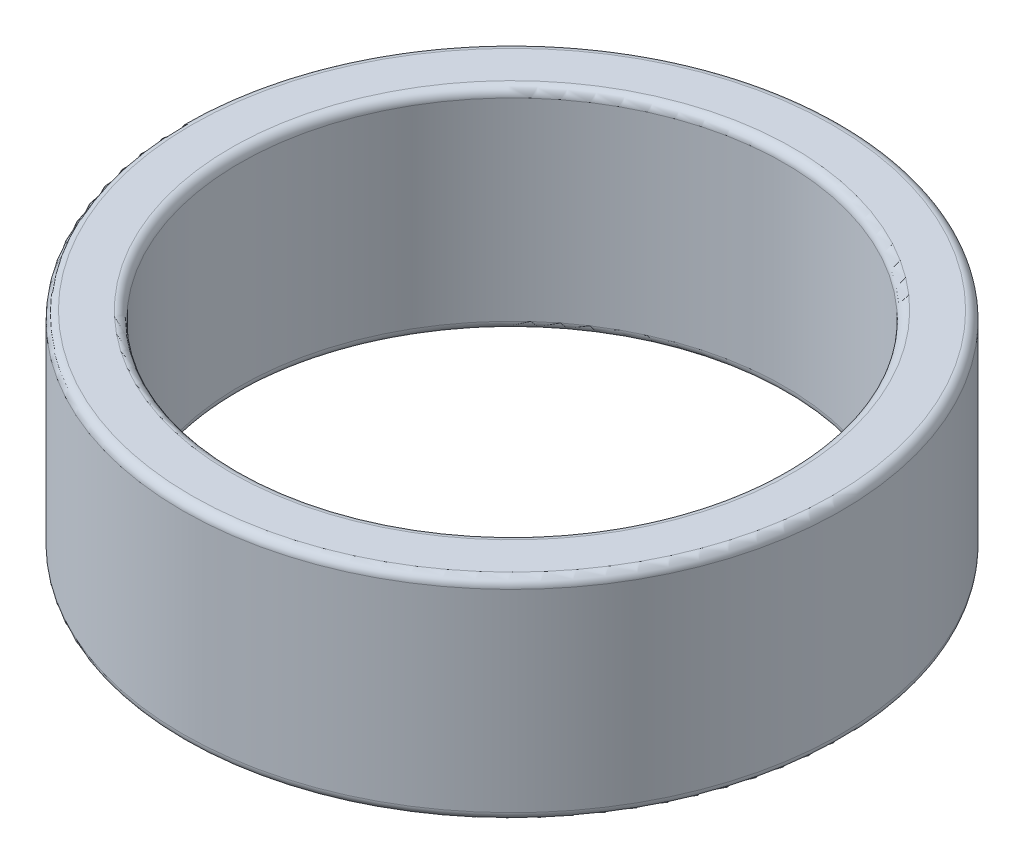
from build123d import *

# Parameters (mm, degrees)
ESQUISSE1_R        = 18.75
ESQUISSE1_R_2      = 15.5
BOSS_EXTRU_1_DEPTH = 12
CONG_1_R           = 0.5


with BuildPart() as part:
    # Esquisse1 → Boss.-Extru.1 (new body)
    with BuildSketch(Plane(origin=(0, 0, 0), x_dir=(1, 0, 0), z_dir=(0, 1, 0))):
        with Locations(Location((0, 0, 0), (0, 0, 270))):  # turned: the seam where the file's is
            Circle(ESQUISSE1_R)
        with Locations(Location((0, 0, 0), (0, 0, 270))):  # turned: the seam where the file's is
            Circle(ESQUISSE1_R_2, mode=Mode.SUBTRACT)
    extrude(amount=BOSS_EXTRU_1_DEPTH)

    # Congé1
    cong_1_edges = [part.edges().sort_by_distance(p)[0] for p in [
        (0, 0, -18.75),
        (0, 12, -18.75),
        (0, 0, -15.5),
        (0, 12, -15.5),
    ]]
    fillet(cong_1_edges, radius=CONG_1_R)


solid = part.part
